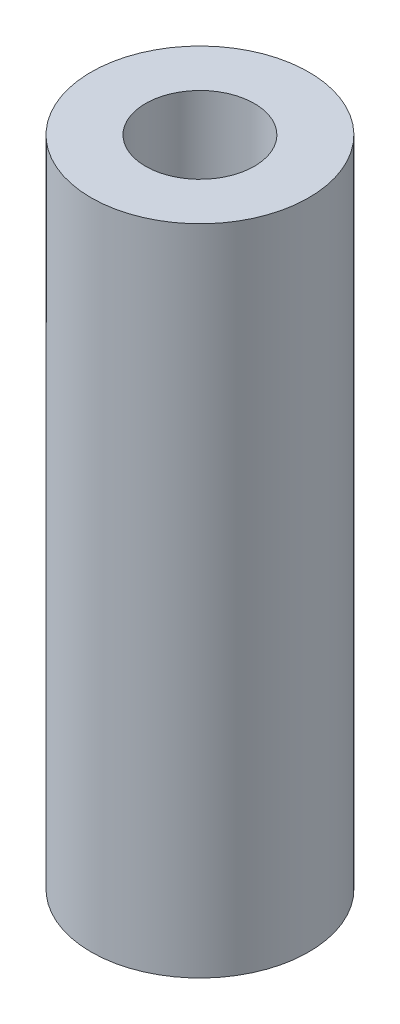
from build123d import *

# Parameters (mm, degrees)
SKETCH1_R           = 5
SKETCH1_R_2         = 2.5
BOSS_EXTRUDE1_DEPTH = 30


with BuildPart() as part:
    # Sketch1 → Boss-Extrude1 (new body)
    with BuildSketch(Plane(origin=(0, 0, 0), x_dir=(1, 0, 0), z_dir=(0, 1, 0))):
        Circle(SKETCH1_R)
        Circle(SKETCH1_R_2, mode=Mode.SUBTRACT)
    extrude(amount=BOSS_EXTRUDE1_DEPTH)


solid = part.part
